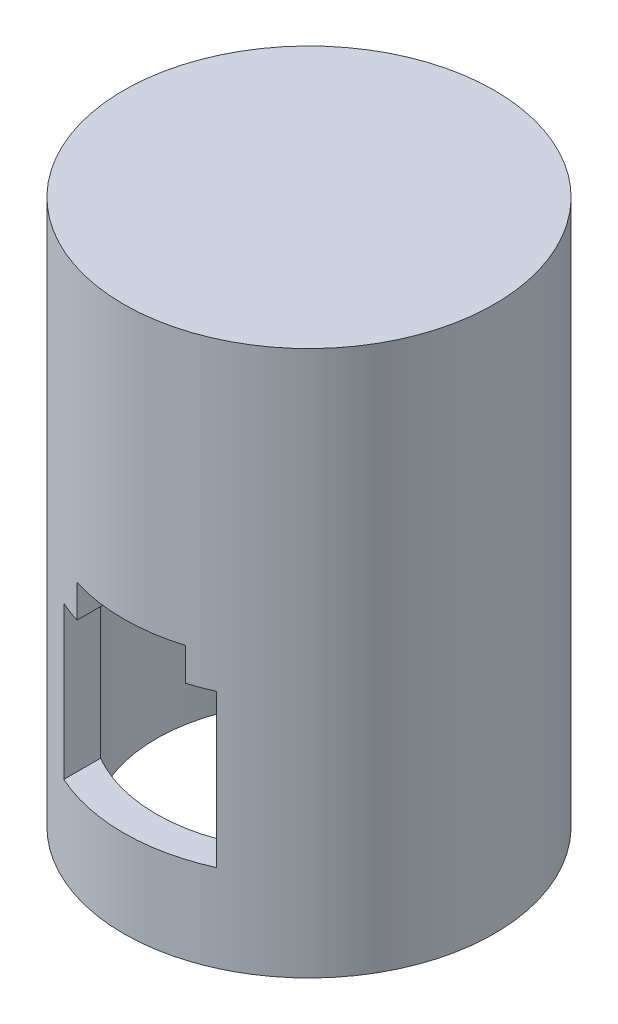
from build123d import *

# Parameters (mm, degrees)
SKETCH1_R               = 17
BOSS_EXTRUDE1_DEPTH     = 30
SKETCH2_R               = 14
CUT_EXTRUDE1_DEPTH      = 30
SKETCH3_W               = 14
SKETCH3_H               = 14
CUT_EXTRUDE2_DEPTH      = 18
CUT_EXTRUDE2_DEPTH_BACK = 18
SKETCH4_R               = 17
BOSS_EXTRUDE2_DEPTH     = 20
SKETCH6_W               = 10
SKETCH6_H               = 6
CUT_EXTRUDE3_DEPTH      = 18
CUT_EXTRUDE3_DEPTH_BACK = 18


with BuildPart() as part:
    # Sketch1 → Boss-Extrude1 (new body)
    with BuildSketch(Plane(origin=(0, 0, 0), x_dir=(1, 0, 0), z_dir=(0, 1, 0))):
        Circle(SKETCH1_R)
    extrude(amount=BOSS_EXTRUDE1_DEPTH)

    # Sketch2 → Cut-Extrude1 (cut)
    with BuildSketch(Plane(origin=(0, 30, 0), x_dir=(1, 0, 0), z_dir=(0, 1, 0))):
        Circle(SKETCH2_R)
    extrude(amount=-CUT_EXTRUDE1_DEPTH, mode=Mode.SUBTRACT)

    # Sketch3 → Cut-Extrude2 (cut, two sides)
    with BuildSketch(Plane.XY) as cut_extrude2_sk:
        with Locations((0, 15)):
            Rectangle(SKETCH3_W, SKETCH3_H)
    extrude(amount=CUT_EXTRUDE2_DEPTH, mode=Mode.SUBTRACT)
    extrude(cut_extrude2_sk.sketch, amount=-CUT_EXTRUDE2_DEPTH_BACK, mode=Mode.SUBTRACT)

    # Sketch4 → Boss-Extrude2 (add)
    with BuildSketch(Plane(origin=(0, 30, 0), x_dir=(1, 0, 0), z_dir=(0, 1, 0))):
        Circle(SKETCH4_R)
    extrude(amount=BOSS_EXTRUDE2_DEPTH)

    # Sketch6 → Cut-Extrude3 (cut, two sides)
    with BuildSketch(Plane.XY) as cut_extrude3_sk:
        with Locations((-0.049003827, 22)):
            Rectangle(SKETCH6_W, SKETCH6_H)
    extrude(amount=CUT_EXTRUDE3_DEPTH, mode=Mode.SUBTRACT)
    extrude(cut_extrude3_sk.sketch, amount=-CUT_EXTRUDE3_DEPTH_BACK, mode=Mode.SUBTRACT)


solid = part.part
